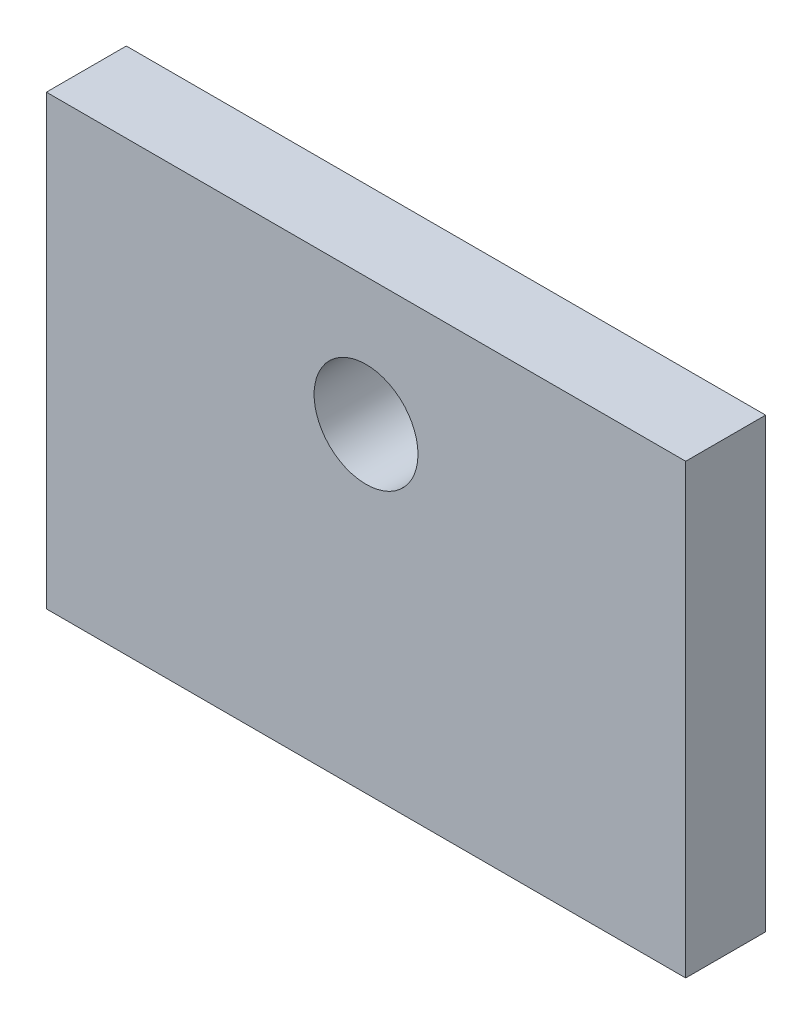
from build123d import *

# Parameters (mm, degrees)
SKETCH_1_W      = 80
SKETCH_1_H      = 56
SKETCH_1_R      = 6.5
EXTRUDE_1_DEPTH = 10


with BuildPart() as part:
    # 草图1 → 凸台-拉伸1 (new body)
    with BuildSketch(Plane.XY):
        with Locations((3.887147335, 0.589341693)):
            Rectangle(SKETCH_1_W, SKETCH_1_H)
        with Locations((3.887147335, 12.589341693)):
            Circle(SKETCH_1_R, mode=Mode.SUBTRACT)
    extrude(amount=EXTRUDE_1_DEPTH)


solid = part.part
